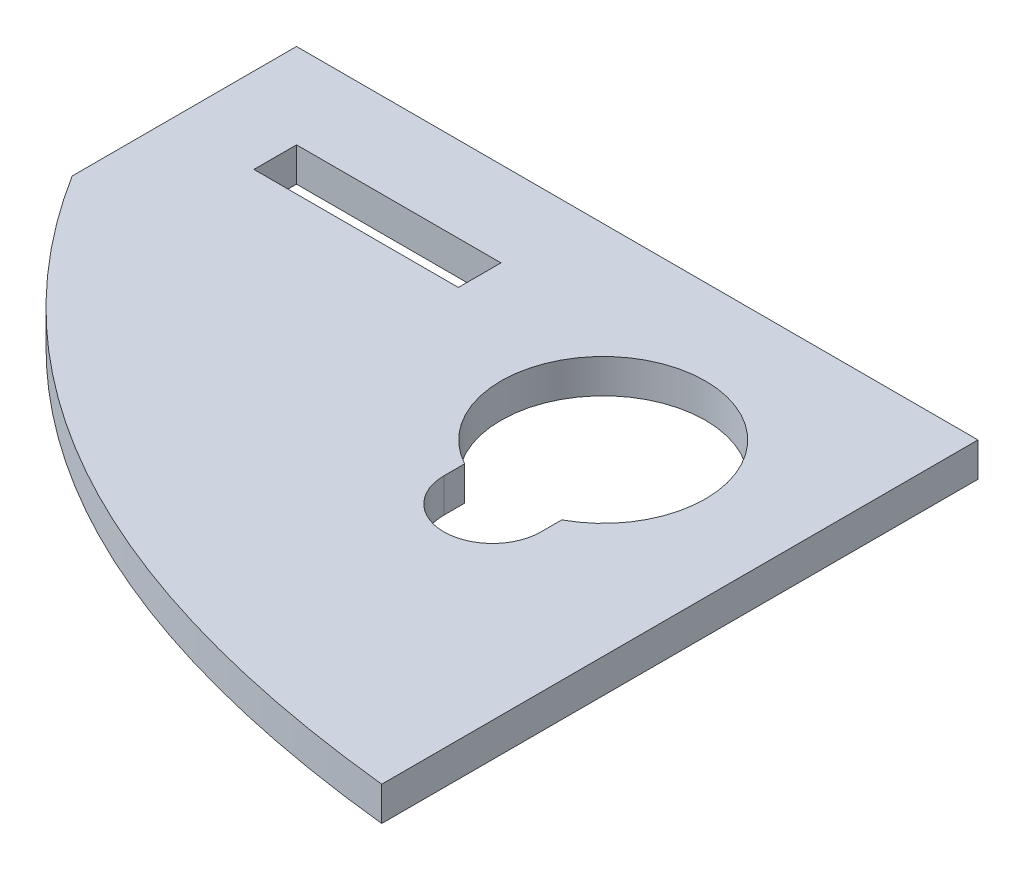
from build123d import *

# Parameters (mm, degrees)
ESQUISSE1_W             = 40
ESQUISSE1_H             = 35
ESQUISSE1_W_2           = 12
ESQUISSE1_H_2           = 2.5
BOSS_EXTRU_1_DEPTH      = 2
ENL_V_MAT_EXTRU_1_DEPTH = 10


with BuildPart() as part:
    # Esquisse1 → Boss.-Extru.1 (new body)
    with BuildSketch(Plane(origin=(0, 0, 0), x_dir=(1, 0, 0), z_dir=(0, 1, 0))):
        Rectangle(ESQUISSE1_W, ESQUISSE1_H)
        with BuildLine():
            Line((6.15, 1.220085228), (6.15, 0))
            ThreePointArc((6.15, 0), (9, -2.85), (11.85, 0))
            Line((11.85, 0), (11.85, 1.220085228))
            ThreePointArc((11.85, 1.220085228), (9, 12.5), (6.15, 1.220085228))
        make_face(mode=Mode.SUBTRACT)
        with Locations((-9, 11.25)):
            Rectangle(ESQUISSE1_W_2, ESQUISSE1_H_2, mode=Mode.SUBTRACT)
    extrude(amount=BOSS_EXTRU_1_DEPTH)

    # Esquisse2 → Enlèv. mat.-Extru.1 (cut)
    with BuildSketch(Plane(origin=(0, 2, 0), x_dir=(1, 0, 0), z_dir=(0, 1, 0))):
        with BuildLine():
            Line((-24.036917244, 12.452787924), (-23.501994654, -22.917521082))
            Line((-23.501994654, -22.917521082), (20, -17.5))
            add(Edge.make_bspline(
                [(20, -17.5), (-13.836799154, -13.898150417), (-24.036917244, 12.452787924)],
                knots=[0, 0, 0, 1, 1, 1], degree=2))
        make_face()
    extrude(amount=-ENL_V_MAT_EXTRU_1_DEPTH, mode=Mode.SUBTRACT)


solid = part.part
